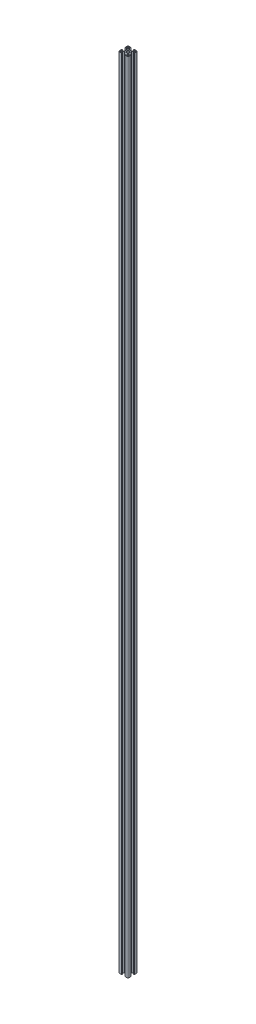
from build123d import *

# Parameters (mm, degrees)
SKETCH_3_R      = 3.4
EXTRUDE_1_DEPTH = 2488


with BuildPart() as part:
    # 草图3 → 凸台-拉伸1 (new body)
    with BuildSketch(Plane(origin=(0, 0, 0), x_dir=(1, 0, 0), z_dir=(0, 1, 0))):
        with BuildLine():
            Line((-15, -12.5), (-15, -5.4))
            ThreePointArc((-15, -5.4), (-14.941421356, -5.258578644), (-14.8, -5.2))
            Line((-14.8, -5.2), (-14.4, -5.2))
            ThreePointArc((-14.4, -5.2), (-14.258578644, -5.141421356), (-14.2, -5))
            Line((-14.2, -5), (-14.2, -4.3))
            ThreePointArc((-14.2, -4.3), (-14.141421356, -4.158578644), (-14, -4.1))
            Line((-14, -4.1), (-13.2, -4.1))
            Line((-13.2, -4.1), (-13.2, -8.25))
            Line((-13.2, -8.25), (-9.522792206, -8.25))
            Line((-9.522792206, -8.25), (-5.8, -4.527207794))
            Line((-5.8, -4.527207794), (-5.8, 4.527207794))
            Line((-5.8, 4.527207794), (-9.522792206, 8.25))
            Line((-9.522792206, 8.25), (-13.2, 8.25))
            Line((-13.2, 8.25), (-13.2, 4.1))
            Line((-13.2, 4.1), (-14, 4.1))
            ThreePointArc((-14, 4.1), (-14.141421356, 4.158578644), (-14.2, 4.3))
            Line((-14.2, 4.3), (-14.2, 5))
            ThreePointArc((-14.2, 5), (-14.258578644, 5.141421356), (-14.4, 5.2))
            Line((-14.4, 5.2), (-14.8, 5.2))
            ThreePointArc((-14.8, 5.2), (-14.941421356, 5.258578644), (-15, 5.4))
            Line((-15, 5.4), (-15, 12.5))
            ThreePointArc((-15, 12.5), (-14.267766953, 14.267766953), (-12.5, 15))
            Line((-12.5, 15), (-5.4, 15))
            ThreePointArc((-5.4, 15), (-5.258578644, 14.941421356), (-5.2, 14.8))
            Line((-5.2, 14.8), (-5.2, 14.4))
            ThreePointArc((-5.2, 14.4), (-5.141421356, 14.258578644), (-5, 14.2))
            Line((-5, 14.2), (-4.3, 14.2))
            ThreePointArc((-4.3, 14.2), (-4.158578644, 14.141421356), (-4.1, 14))
            Line((-4.1, 14), (-4.1, 13.2))
            Line((-4.1, 13.2), (-8.25, 13.2))
            Line((-8.25, 13.2), (-8.25, 9.522792206))
            Line((-8.25, 9.522792206), (-4.527207794, 5.8))
            Line((-4.527207794, 5.8), (4.527207794, 5.8))
            Line((4.527207794, 5.8), (8.25, 9.522792206))
            Line((8.25, 9.522792206), (8.25, 13.2))
            Line((8.25, 13.2), (4.1, 13.2))
            Line((4.1, 13.2), (4.1, 14))
            ThreePointArc((4.1, 14), (4.158578644, 14.141421356), (4.3, 14.2))
            Line((4.3, 14.2), (5, 14.2))
            ThreePointArc((5, 14.2), (5.141421356, 14.258578644), (5.2, 14.4))
            Line((5.2, 14.4), (5.2, 14.8))
            ThreePointArc((5.2, 14.8), (5.258578644, 14.941421356), (5.4, 15))
            Line((5.4, 15), (12.5, 15))
            ThreePointArc((12.5, 15), (14.267766953, 14.267766953), (15, 12.5))
            Line((15, 12.5), (15, 5.4))
            ThreePointArc((15, 5.4), (14.941421356, 5.258578644), (14.8, 5.2))
            Line((14.8, 5.2), (14.4, 5.2))
            ThreePointArc((14.4, 5.2), (14.258578644, 5.141421356), (14.2, 5))
            Line((14.2, 5), (14.2, 4.3))
            ThreePointArc((14.2, 4.3), (14.141421356, 4.158578644), (14, 4.1))
            Line((14, 4.1), (13.2, 4.1))
            Line((13.2, 4.1), (13.2, 8.25))
            Line((13.2, 8.25), (9.522792206, 8.25))
            Line((9.522792206, 8.25), (5.8, 4.527207794))
            Line((5.8, 4.527207794), (5.8, -4.527207794))
            Line((5.8, -4.527207794), (9.522792206, -8.25))
            Line((9.522792206, -8.25), (13.2, -8.25))
            Line((13.2, -8.25), (13.2, -4.1))
            Line((13.2, -4.1), (14, -4.1))
            ThreePointArc((14, -4.1), (14.141421356, -4.158578644), (14.2, -4.3))
            Line((14.2, -4.3), (14.2, -5))
            ThreePointArc((14.2, -5), (14.258578644, -5.141421356), (14.4, -5.2))
            Line((14.4, -5.2), (14.8, -5.2))
            ThreePointArc((14.8, -5.2), (14.941421356, -5.258578644), (15, -5.4))
            Line((15, -5.4), (15, -12.5))
            ThreePointArc((15, -12.5), (14.267766953, -14.267766953), (12.5, -15))
            Line((12.5, -15), (5.4, -15))
            ThreePointArc((5.4, -15), (5.258578644, -14.941421356), (5.2, -14.8))
            Line((5.2, -14.8), (5.2, -14.4))
            ThreePointArc((5.2, -14.4), (5.141421356, -14.258578644), (5, -14.2))
            Line((5, -14.2), (4.3, -14.2))
            ThreePointArc((4.3, -14.2), (4.158578644, -14.141421356), (4.1, -14))
            Line((4.1, -14), (4.1, -13.2))
            Line((4.1, -13.2), (8.25, -13.2))
            Line((8.25, -13.2), (8.25, -9.522792206))
            Line((8.25, -9.522792206), (4.527207794, -5.8))
            Line((4.527207794, -5.8), (-4.527207794, -5.8))
            Line((-4.527207794, -5.8), (-8.25, -9.522792206))
            Line((-8.25, -9.522792206), (-8.25, -13.2))
            Line((-8.25, -13.2), (-4.1, -13.2))
            Line((-4.1, -13.2), (-4.1, -14))
            ThreePointArc((-4.1, -14), (-4.158578644, -14.141421356), (-4.3, -14.2))
            Line((-4.3, -14.2), (-5, -14.2))
            ThreePointArc((-5, -14.2), (-5.141421356, -14.258578644), (-5.2, -14.4))
            Line((-5.2, -14.4), (-5.2, -14.8))
            ThreePointArc((-5.2, -14.8), (-5.258578644, -14.941421356), (-5.4, -15))
            Line((-5.4, -15), (-12.5, -15))
            ThreePointArc((-12.5, -15), (-14.267766953, -14.267766953), (-15, -12.5))
        make_face()
        Circle(SKETCH_3_R, mode=Mode.SUBTRACT)
        with BuildLine():
            Line((-13.2, -12.2), (-13.2, -11.05))
            ThreePointArc((-13.2, -11.05), (-12.907106781, -10.342893219), (-12.2, -10.05))
            Line((-12.2, -10.05), (-11.05, -10.05))
            ThreePointArc((-11.05, -10.05), (-10.342893219, -10.342893219), (-10.05, -11.05))
            Line((-10.05, -11.05), (-10.05, -12.2))
            ThreePointArc((-10.05, -12.2), (-10.342893219, -12.907106781), (-11.05, -13.2))
            Line((-11.05, -13.2), (-12.2, -13.2))
            ThreePointArc((-12.2, -13.2), (-12.907106781, -12.907106781), (-13.2, -12.2))
        make_face(mode=Mode.SUBTRACT)
        with BuildLine():
            Line((-10.05, 12.2), (-10.05, 11.05))
            ThreePointArc((-10.05, 11.05), (-10.342893219, 10.342893219), (-11.05, 10.05))
            Line((-11.05, 10.05), (-12.2, 10.05))
            ThreePointArc((-12.2, 10.05), (-12.907106781, 10.342893219), (-13.2, 11.05))
            Line((-13.2, 11.05), (-13.2, 12.2))
            ThreePointArc((-13.2, 12.2), (-12.907106781, 12.907106781), (-12.2, 13.2))
            Line((-12.2, 13.2), (-11.05, 13.2))
            ThreePointArc((-11.05, 13.2), (-10.342893219, 12.907106781), (-10.05, 12.2))
        make_face(mode=Mode.SUBTRACT)
        with BuildLine():
            Line((13.2, 12.2), (13.2, 11.05))
            ThreePointArc((13.2, 11.05), (12.907106781, 10.342893219), (12.2, 10.05))
            Line((12.2, 10.05), (11.05, 10.05))
            ThreePointArc((11.05, 10.05), (10.342893219, 10.342893219), (10.05, 11.05))
            Line((10.05, 11.05), (10.05, 12.2))
            ThreePointArc((10.05, 12.2), (10.342893219, 12.907106781), (11.05, 13.2))
            Line((11.05, 13.2), (12.2, 13.2))
            ThreePointArc((12.2, 13.2), (12.907106781, 12.907106781), (13.2, 12.2))
        make_face(mode=Mode.SUBTRACT)
        with BuildLine():
            Line((10.05, -12.2), (10.05, -11.05))
            ThreePointArc((10.05, -11.05), (10.342893219, -10.342893219), (11.05, -10.05))
            Line((11.05, -10.05), (12.2, -10.05))
            ThreePointArc((12.2, -10.05), (12.907106781, -10.342893219), (13.2, -11.05))
            Line((13.2, -11.05), (13.2, -12.2))
            ThreePointArc((13.2, -12.2), (12.907106781, -12.907106781), (12.2, -13.2))
            Line((12.2, -13.2), (11.05, -13.2))
            ThreePointArc((11.05, -13.2), (10.342893219, -12.907106781), (10.05, -12.2))
        make_face(mode=Mode.SUBTRACT)
    extrude(amount=EXTRUDE_1_DEPTH)


solid = part.part
